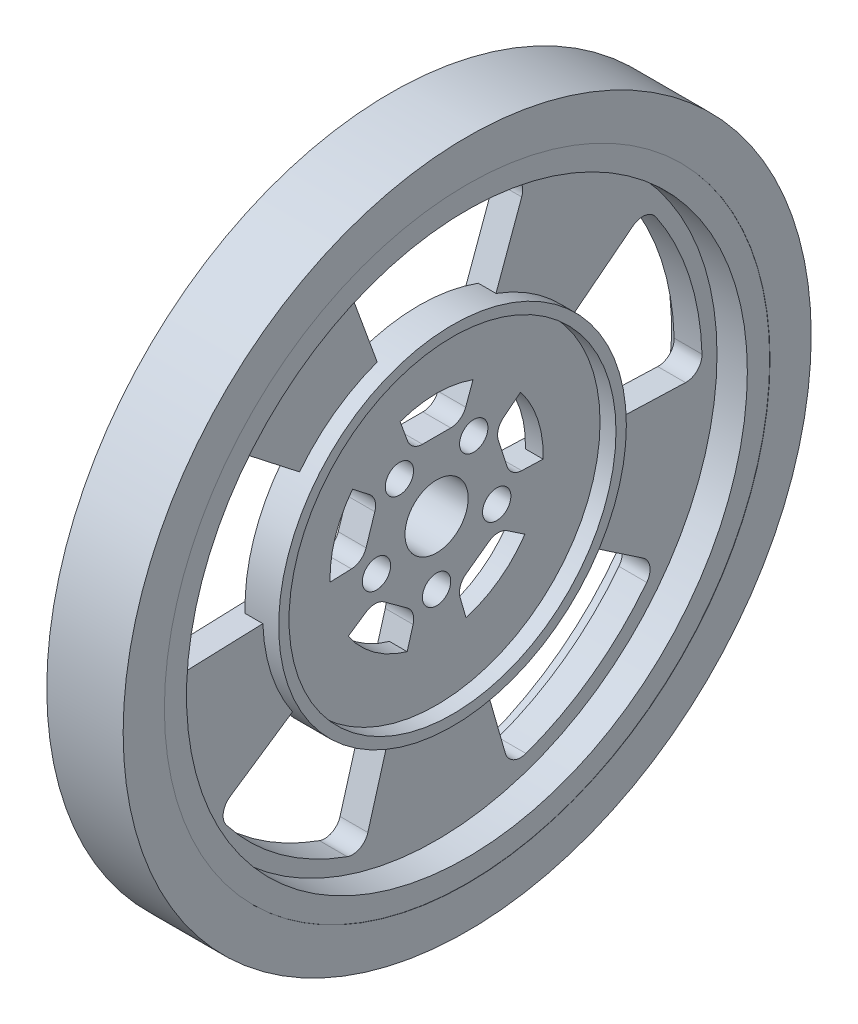
from build123d import *

# Parameters (mm, degrees)
SKETCH1_R                = 34.544
BOSS_EXTRUDE1_DEPTH      = 7.62
SKETCH2_R                = 28.1686
CUT_EXTRUDE1_DEPTH       = 3.048
CUT_EXTRUDE2_START       = -1.778
SKETCH3_R                = 28.1686
SKETCH3_R_2              = 4.3688
CUT_EXTRUDE2_DEPTH       = 1.778
CUT_EXTRUDE3_DEPTH       = 50.200658898
FILLET1_R                = 1.6002
CIRPATTERN1_COUNT        = 5
FILLET1_OF_CIRPATTERN1_R = 1.6002
SKETCH5_R                = 17.4625
SKETCH5_R_2              = 10.7061
BOSS_EXTRUDE2_DEPTH      = 1.778
BOSS_EXTRUDE4_START      = 1.6002
SKETCH6_R                = 17.4625
SKETCH6_R_2              = 16.4211
BOSS_EXTRUDE4_DEPTH      = 1.6002
SKETCH7_R                = 3.175
CUT_EXTRUDE4_DEPTH       = 50.066068275
SKETCH8_R                = 1.4224
CUT_EXTRUDE5_DEPTH       = 50.066068275
CIRPATTERN2_COUNT        = 5
BOSS_EXTRUDE5_DEPTH      = 0.0254
BOSS_EXTRUDE5_DEPTH_BACK = 7.6454
SKETCH9_R                = 34.5567
SKETCH9_R_2              = 30.4165


with BuildPart() as part:
    # Sketch1 → Boss-Extrude1 (new body)
    with BuildSketch(Plane(origin=(0, 0, 0), x_dir=(0, 0, -1), z_dir=(1, 0, 0))):
        with Locations(Location((0, 0, 0), (0, 0, 180))):
            Circle(SKETCH1_R)
    extrude(amount=BOSS_EXTRUDE1_DEPTH)

    # Sketch2 → Cut-Extrude1 (cut)
    with BuildSketch(Plane(origin=(7.62, 0, 0), x_dir=(0, 0, -1), z_dir=(1, 0, 0))):
        Circle(SKETCH2_R)
    extrude(amount=-CUT_EXTRUDE1_DEPTH, mode=Mode.SUBTRACT)

    # Sketch3 → Cut-Extrude2 (cut)
    with BuildSketch(Plane.ZY.offset(CUT_EXTRUDE2_START)):
        with Locations(Location((0, 0, 0), (0, 0, 180))):
            Circle(SKETCH3_R)
        Circle(SKETCH3_R_2, mode=Mode.SUBTRACT)
    extrude(amount=CUT_EXTRUDE2_DEPTH, mode=Mode.SUBTRACT)

    # Sketch4 → Cut-Extrude3 (cut, through all)
    with BuildSketch(Plane.ZY.offset(-1.778)):
        with BuildLine():
            Line((-2.54, 6.985), (2.54, 6.985))
            Line((2.54, 6.985), (9.114287493, 25.064290604))
            ThreePointArc((9.114287493, 25.064290604), (0, 26.67), (-9.114287493, 25.064290604))
            Line((-9.114287493, 25.064290604), (-2.54, 6.985))
        make_face()
    cut_extrude3 = extrude(amount=-CUT_EXTRUDE3_DEPTH, mode=Mode.SUBTRACT)

    # Fillet1
    fillet1_edges = [part.edges().sort_by_distance(p)[0] for p in [
        (3.175, 25.064290604, 9.114287493),
        (3.175, 6.985, 2.54),
        (3.175, 6.985, -2.54),
        (3.175, 25.064290604, -9.114287493),
    ]]
    fillet(fillet1_edges, radius=FILLET1_R)

    # CirPattern1: Cut-Extrude3 ×5 about axis
    cirpattern1_axis = Axis((0, 0, 0), (1, 0, 0))
    for i in range(1, CIRPATTERN1_COUNT):
        add(cut_extrude3.rotate(cirpattern1_axis, i * 360 / CIRPATTERN1_COUNT), mode=Mode.SUBTRACT)

    # Fillet1 of CirPattern1
    fillet1_of_cirpattern1_edges = [part.edges().sort_by_distance(p)[0] for p in [
        (3.175, -0.922910762, 26.654026632),
        (3.175, -0.257199846, 7.428032932),
        (3.175, 4.574167257, 5.858226601),
        (3.175, 16.41349426, 21.021087179),
        (3.175, -25.634680824, 7.358806903),
        (3.175, -7.143958247, 2.050776822),
        (3.175, -4.158009165, 6.160583153),
        (3.175, -14.920193278, 22.10603385),
        (3.175, -14.920193278, -22.10603385),
        (3.175, -4.158009165, -6.160583153),
        (3.175, -7.143958247, -2.050776822),
        (3.175, -25.634680824, -7.358806903),
        (3.175, 16.41349426, -21.021087179),
        (3.175, 4.574167257, -5.858226601),
        (3.175, -0.257199846, -7.428032932),
        (3.175, -0.922910762, -26.654026632),
    ]]
    fillet(fillet1_of_cirpattern1_edges, radius=FILLET1_OF_CIRPATTERN1_R)

    # Sketch5 → Boss-Extrude2 (add)
    with BuildSketch(Plane(origin=(4.572, 0, 0), x_dir=(0, 0, -1), z_dir=(1, 0, 0))):
        Circle(SKETCH5_R)
        Circle(SKETCH5_R_2, mode=Mode.SUBTRACT)
    extrude(amount=-BOSS_EXTRUDE2_DEPTH)

    # Sketch6 → Boss-Extrude4 (add)
    with BuildSketch(Plane(origin=(4.572, 0, 0), x_dir=(0, 0, -1), z_dir=(1, 0, 0)).offset(BOSS_EXTRUDE4_START)):
        Circle(SKETCH6_R)
        Circle(SKETCH6_R_2, mode=Mode.SUBTRACT)
    extrude(amount=-BOSS_EXTRUDE4_DEPTH)

    # Sketch7 → Cut-Extrude4 (cut, through all)
    with BuildSketch(Plane(origin=(4.572, 0, 0), x_dir=(0, 0, -1), z_dir=(1, 0, 0))):
        Circle(SKETCH7_R)
    extrude(amount=-CUT_EXTRUDE4_DEPTH, mode=Mode.SUBTRACT)

    # Sketch8 → Cut-Extrude5 (cut, through all)
    with BuildSketch(Plane(origin=(4.572, 0, 0), x_dir=(0, 0, -1), z_dir=(1, 0, 0))):
        with Locations((0, -6.35)):
            Circle(SKETCH8_R)
    cut_extrude5 = extrude(amount=-CUT_EXTRUDE5_DEPTH, mode=Mode.SUBTRACT)

    # CirPattern2: Cut-Extrude5 ×5 about axis
    cirpattern2_axis = Axis((0, 0, 0), (1, 0, 0))
    for i in range(1, CIRPATTERN2_COUNT):
        add(cut_extrude5.rotate(cirpattern2_axis, i * 360 / CIRPATTERN2_COUNT), mode=Mode.SUBTRACT)

    # Sketch9 → Boss-Extrude5 (add, two sides: drawn at the far end of the back side and taken through both)
    with BuildSketch(Plane(origin=(7.62, 0, 0), x_dir=(0, 0, -1), z_dir=(1, 0, 0)).offset(-BOSS_EXTRUDE5_DEPTH_BACK)):
        Circle(SKETCH9_R)
        Circle(SKETCH9_R_2, mode=Mode.SUBTRACT)
    extrude(amount=BOSS_EXTRUDE5_DEPTH + BOSS_EXTRUDE5_DEPTH_BACK)


solid = part.part
